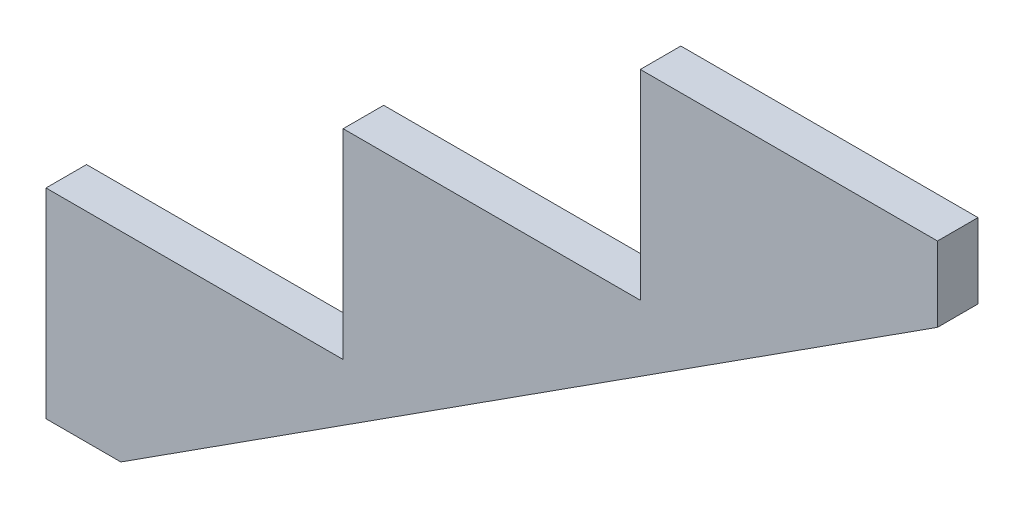
from build123d import *

# Parameters (mm, degrees)
BOSS_EXTRUDE1_DEPTH = 38.1


with BuildPart() as part:
    # Sketch1 → Boss-Extrude1 (new body)
    with BuildSketch(Plane.XY):
        Polygon((0, 187.96), (0, 0), (70.348296425, 0), (838.2, 493.531703575), (838.2, 563.88), (558.8, 563.88), (558.8, 375.92), (279.4, 375.92), (279.4, 187.96), align=None)
    extrude(amount=BOSS_EXTRUDE1_DEPTH)


solid = part.part
